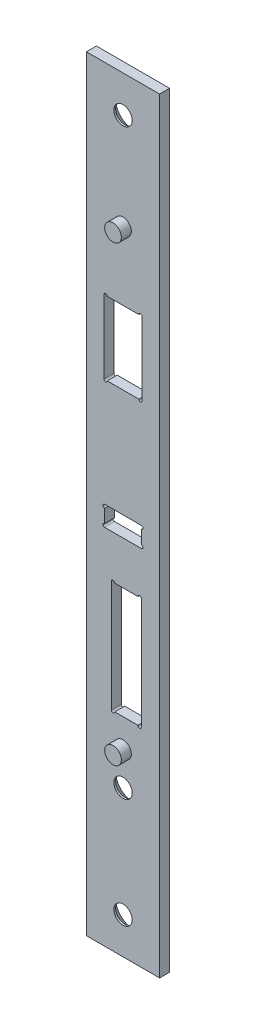
from build123d import *

# Parameters (mm, degrees)
ESQUISSE1_W                                    = 22
ESQUISSE1_H                                    = 230
EXTRUSION1_DEPTH                               = 1.5
DIAM_TRE_DU_PER_AGE_0_3_0_3_1_D                = 0.3
DIAM_TRE_DU_PER_AGE_0_3_0_3_1_DEPTH            = 3
DIAM_TRE_DU_PER_AGE_0_3_0_3_1_TIP              = 0.090129093
ENL_V_MAT_EXTRU_1_REACH                        = 5
ENL_V_MAT_EXTRU_2_REACH                        = 5
ENL_V_MAT_EXTRU_3_REACH                        = 5
ESQUISSE10_R                                   = 2.5
EXTRUSION2_DEPTH                               = 3
FRAISAGE_POUR_VIS_T_TE_FRAIS_E_M52_D           = 5.5
FRAISAGE_POUR_VIS_T_TE_FRAIS_E_M52_CSINK_D     = 10.4
FRAISAGE_POUR_VIS_T_TE_FRAIS_E_M52_CSINK_ANGLE = 90


with BuildPart() as part:
    # Esquisse1 → Extrusion1 (new body, symmetric)
    with BuildSketch(Plane.XY):
        Rectangle(ESQUISSE1_W, ESQUISSE1_H)
    extrude(amount=EXTRUSION1_DEPTH, both=True)

    # Diamètre du perçage Ø0.3 (0.3)1
    with Locations(Plane.XY.offset(1.5)):
        with Locations((0, 104), (0, -71), (0, -104)):
            Hole(DIAM_TRE_DU_PER_AGE_0_3_0_3_1_D / 2, depth=DIAM_TRE_DU_PER_AGE_0_3_0_3_1_DEPTH)
            with Locations((0, 0, -(DIAM_TRE_DU_PER_AGE_0_3_0_3_1_DEPTH + DIAM_TRE_DU_PER_AGE_0_3_0_3_1_TIP / 2))):  # 118° drill point
                Cone(0, DIAM_TRE_DU_PER_AGE_0_3_0_3_1_D / 2, DIAM_TRE_DU_PER_AGE_0_3_0_3_1_TIP, mode=Mode.SUBTRACT)

    # Esquisse7 → Enlèv. mat.-Extru.1 (cut, up to next)
    with BuildSketch(Plane.XY.offset(1.5), mode=Mode.PRIVATE) as enl_v_mat_extru_1_sk1:
        with BuildLine():
            Line((-4.75, 54.5), (4.75, 54.5))
            ThreePointArc((4.75, 54.5), (5.25, 55), (5.75, 54.5))
            Line((5.75, 54.5), (5.75, 32.5))
            ThreePointArc((5.75, 32.5), (5.25, 32), (4.75, 32.5))
            Line((4.75, 32.5), (-4.75, 32.5))
            ThreePointArc((-4.75, 32.5), (-5.25, 32), (-5.75, 32.5))
            Line((-5.75, 32.5), (-5.75, 54.5))
            ThreePointArc((-5.75, 54.5), (-5.25, 55), (-4.75, 54.5))
        make_face()
    enl_v_mat_extru_1_tool1 = extrude(enl_v_mat_extru_1_sk1.sketch, amount=-ENL_V_MAT_EXTRU_1_REACH, mode=Mode.PRIVATE) & part.part
    add(enl_v_mat_extru_1_tool1.solids().sort_by_distance((0, 43.5, 1.5))[0], mode=Mode.SUBTRACT)

    # Esquisse8 → Enlèv. mat.-Extru.2 (cut, up to next)
    with BuildSketch(Plane.XY.offset(1.5), mode=Mode.PRIVATE) as enl_v_mat_extru_2_sk1:
        with BuildLine():
            Line((-5.5, 0), (5.5, 0))
            ThreePointArc((5.5, 0), (6, -0.5), (5.5, -1))
            Line((5.5, -1), (5.5, -5))
            ThreePointArc((5.5, -5), (6, -5.5), (5.5, -6))
            Line((5.5, -6), (-5.5, -6))
            ThreePointArc((-5.5, -6), (-6, -5.5), (-5.5, -5))
            Line((-5.5, -5), (-5.5, -1))
            ThreePointArc((-5.5, -1), (-6, -0.5), (-5.5, 0))
        make_face()
    enl_v_mat_extru_2_tool1 = extrude(enl_v_mat_extru_2_sk1.sketch, amount=-ENL_V_MAT_EXTRU_2_REACH, mode=Mode.PRIVATE) & part.part
    add(enl_v_mat_extru_2_tool1.solids().sort_by_distance((0, -3, 1.5))[0], mode=Mode.SUBTRACT)

    # Esquisse9 → Enlèv. mat.-Extru.3 (cut, up to next)
    with BuildSketch(Plane.XY.offset(1.5), mode=Mode.PRIVATE) as enl_v_mat_extru_3_sk1:
        with BuildLine():
            Line((-2.5, -19), (4.5, -19))
            ThreePointArc((4.5, -19), (5, -18.5), (5.5, -19))
            Line((5.5, -19), (5.5, -52.5))
            ThreePointArc((5.5, -52.5), (5, -53), (4.5, -52.5))
            Line((4.5, -52.5), (-2.5, -52.5))
            ThreePointArc((-2.5, -52.5), (-3, -53), (-3.5, -52.5))
            Line((-3.5, -52.5), (-3.5, -19))
            ThreePointArc((-3.5, -19), (-3, -18.5), (-2.5, -19))
        make_face()
    enl_v_mat_extru_3_tool1 = extrude(enl_v_mat_extru_3_sk1.sketch, amount=-ENL_V_MAT_EXTRU_3_REACH, mode=Mode.PRIVATE) & part.part
    add(enl_v_mat_extru_3_tool1.solids().sort_by_distance((1, -35.75, 1.5))[0], mode=Mode.SUBTRACT)

    # Esquisse10 → Extrusion2 (add)
    with BuildSketch(Plane.XY.offset(1.5)):
        with Locations((0, 75)):
            Circle(ESQUISSE10_R)
        with Locations((0, -61)):
            Circle(ESQUISSE10_R)
    extrude(amount=EXTRUSION2_DEPTH)

    # Fraisage pour vis à tête fraisée M52 (through all)
    with Locations(Plane(origin=(0, -71, -1.5), x_dir=(-1, 0, 0), z_dir=(0, 0, -1))):
        with Locations((0, 0), (0, -33), (0, 175)):
            CounterSinkHole(FRAISAGE_POUR_VIS_T_TE_FRAIS_E_M52_D / 2, FRAISAGE_POUR_VIS_T_TE_FRAIS_E_M52_CSINK_D / 2, counter_sink_angle=FRAISAGE_POUR_VIS_T_TE_FRAIS_E_M52_CSINK_ANGLE)


solid = part.part
